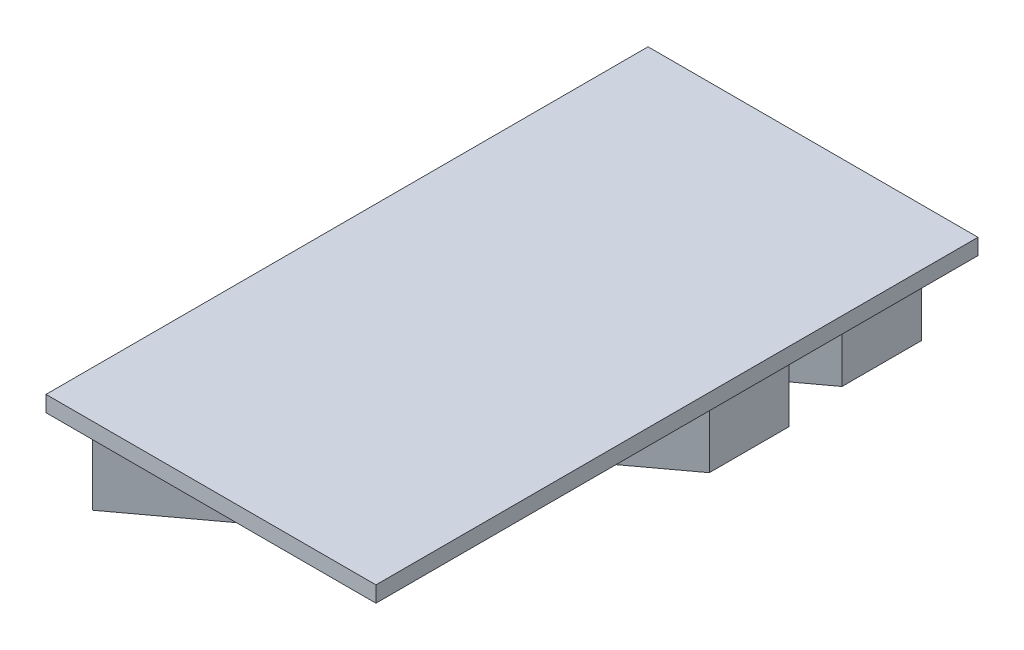
from build123d import *

# Parameters (mm, degrees)
EXTRUDE_1_DEPTH   = 1.5
EXTRUDE_1_2_DEPTH = 1.5
EXTRUDE_1_3_DEPTH = 1.5
SKETCH_2_W        = 6.224573854
SKETCH_2_H        = 11.35798735
EXTRUDE_2_DEPTH   = 0.3


with BuildPart() as part:
    # 草图1 → 凸台-拉伸1 (new body)
    with BuildSketch(Plane(origin=(0, 0, 0), x_dir=(1, 0, 0), z_dir=(0, 1, 0))):
        Polygon((2.250249032, 2.455487133), (2.250249032, 0.954155558), (-3.02390068, -2.945886183), (-3.02390068, -1.444554608), align=None)
    extrude(amount=EXTRUDE_1_DEPTH)



with BuildPart() as body_2:
    # 草图1 → Extrude 1 2 (new body)
    with BuildSketch(Plane(origin=(0, 0, 0), x_dir=(1, 0, 0), z_dir=(0, 1, 0))):
        Polygon((2.093564175, 5.11615287), (2.093564175, 3.614821296), (-0.323874137, 1.827213654), (-0.323874137, 3.328545229), align=None)
    extrude(amount=EXTRUDE_1_2_DEPTH)


with BuildPart() as body_3:
    # 草图1 → Extrude 1 3 (new body)
    with BuildSketch(Plane(origin=(0, 0, 0), x_dir=(1, 0, 0), z_dir=(0, 1, 0))):
        Polygon((-0.539241249, -2.188970073), (-0.539241249, -3.690301647), (-2.956679561, -5.477909289), (-2.956679561, -3.976577714), align=None)
    extrude(amount=EXTRUDE_1_3_DEPTH)


with BuildPart() as part_1:
    add(part.part)

    add(body_2.part)  # 凸台-拉伸2 merges body 2

    add(body_3.part)  # 凸台-拉伸2 merges body 3
    # 草图2 → 凸台-拉伸2 (add)
    with BuildSketch(Plane(origin=(0, 1.5, 0), x_dir=(1, 0, 0), z_dir=(0, 1, 0))):
        with Locations((-0.374426275, -0.143679561)):
            Rectangle(SKETCH_2_W, SKETCH_2_H)
    extrude(amount=EXTRUDE_2_DEPTH)


solid = part_1.part
